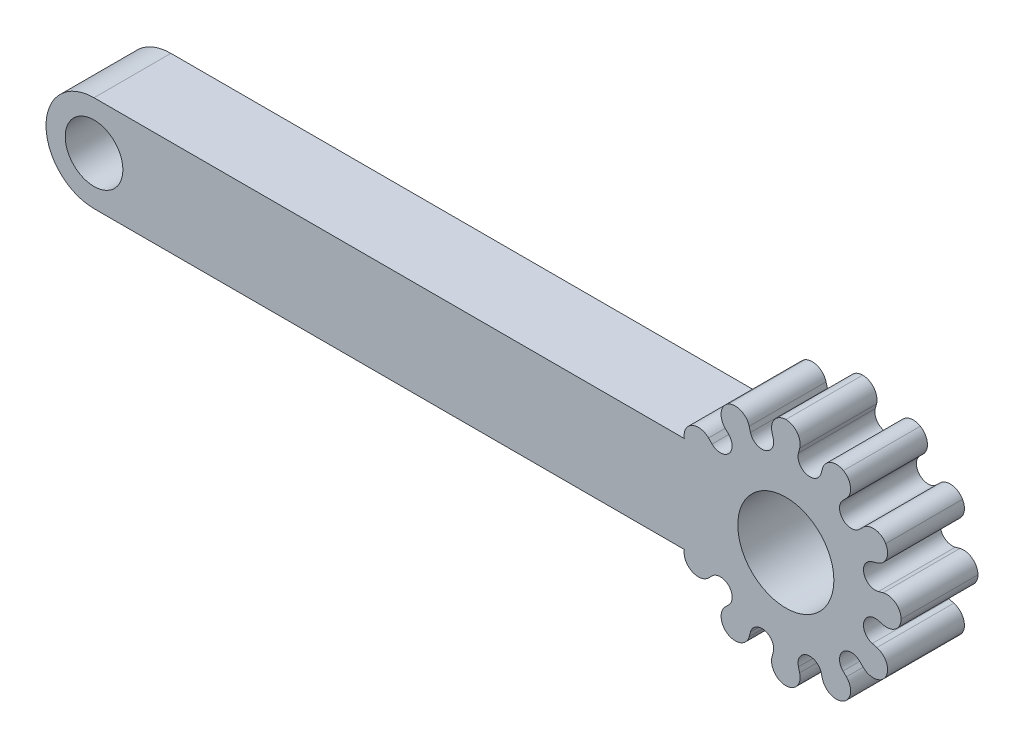
from build123d import *

# Parameters (mm, degrees)
SKETCH1_R           = 1.5
BOSS_EXTRUDE1_DEPTH = 4
CUT_EXTRUDE2_DEPTH  = 5
CIRPATTERN1_COUNT   = 12
SKETCH3_W           = 7.863082298
SKETCH3_H           = 5
BOSS_EXTRUDE2_DEPTH = 4
SKETCH4_R           = 2.5
CUT_EXTRUDE3_DEPTH  = 5


with BuildPart() as part:
    # Sketch1 → Boss-Extrude1 (new body)
    with BuildSketch(Plane.XY):
        with BuildLine():
            Line((-18, 2.5), (12.545643943, 2.5))
            ThreePointArc((12.545643943, 2.5), (24, 0), (12.545643943, -2.5))
            Line((12.545643943, -2.5), (-18, -2.5))
            ThreePointArc((-18, -2.5), (-20.5, 0), (-18, 2.5))
        make_face()
        with Locations((-18, 0)):
            Circle(SKETCH1_R, mode=Mode.SUBTRACT)
    extrude(amount=BOSS_EXTRUDE1_DEPTH)

    # Sketch2 → Cut-Extrude2 (cut, through all)
    with BuildSketch(Plane.XY.offset(4)):
        with BuildLine():
            Line((18.72, 5.06), (18.653012702, 4.81))
            ThreePointArc((18.653012702, 4.81), (19.09327028, 4.061267387), (19.842002893, 4.501524965))
            Line((19.842002893, 4.501524965), (19.906461709, 4.742088543))
            ThreePointArc((19.906461709, 4.742088543), (20.342188248, 5.236548367), (21, 5.196152423))
            ThreePointArc((21, 5.196152423), (19.615923505, 6.030708621), (18, 6))
            ThreePointArc((18, 6), (18.589879661, 5.706078038), (18.72, 5.06))
        make_face()
    cut_extrude2 = extrude(amount=-CUT_EXTRUDE2_DEPTH, mode=Mode.SUBTRACT)

    # CirPattern1: Cut-Extrude2 ×12 about axis
    cirpattern1_axis = Axis((18, 0, 0), (0, 0, 1))
    for i in range(1, CIRPATTERN1_COUNT):
        add(cut_extrude2.rotate(cirpattern1_axis, i * 360 / CIRPATTERN1_COUNT), mode=Mode.SUBTRACT)

    # Sketch3 → Boss-Extrude2 (add)
    with BuildSketch(Plane.XY.offset(4)):
        with Locations((12.029323846, 0)):
            Rectangle(SKETCH3_W, SKETCH3_H)
    extrude(amount=-BOSS_EXTRUDE2_DEPTH)

    # Sketch4 → Cut-Extrude3 (cut, through all)
    with BuildSketch(Plane.XY.offset(4)):
        with Locations((18, 0)):
            Circle(SKETCH4_R)
    extrude(amount=-CUT_EXTRUDE3_DEPTH, mode=Mode.SUBTRACT)


solid = part.part
